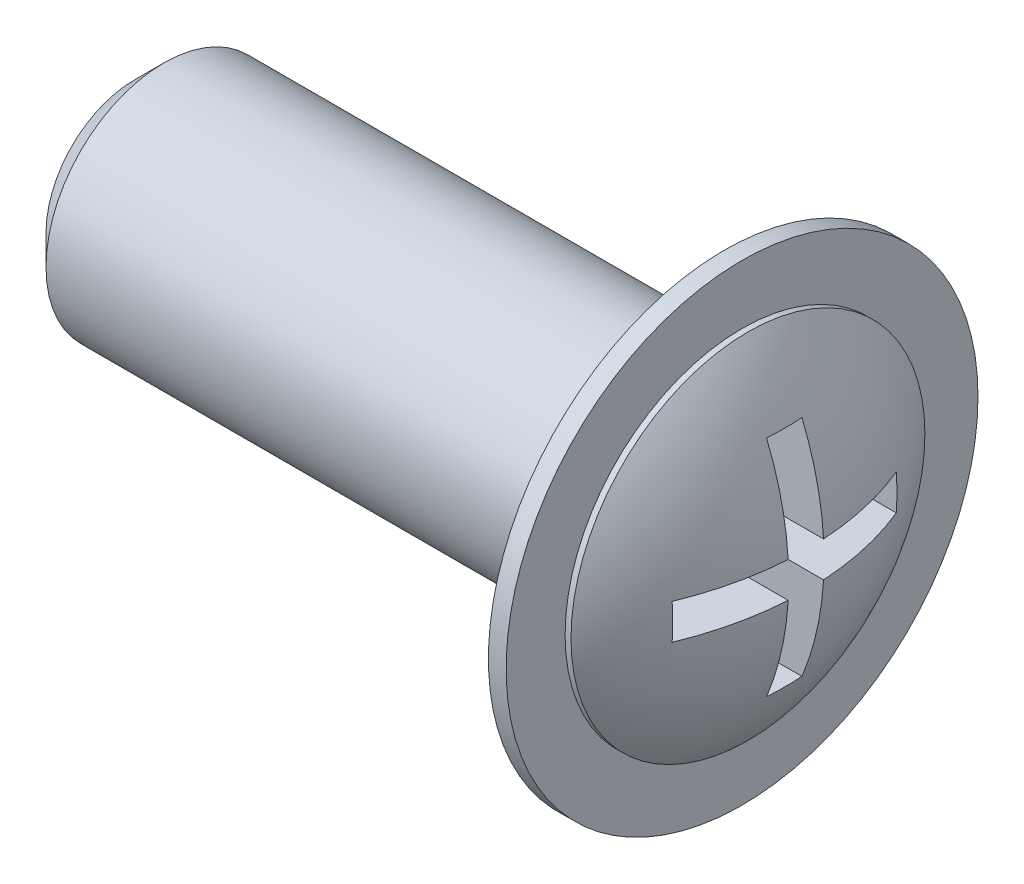
from build123d import *

# Parameters (mm, degrees)
SKETCH_1_R          = 4
EXTRUDE_1_DEPTH     = 0.3
SKETCH_2_R          = 2
EXTRUDE_3_DEPTH     = 10
SKETCH_6_R          = 3
EXTRUDE_4_DEPTH     = 0.1
DOME_1_FACE_RADIUS  = 3
DOME_1_HEIGHT       = 1
CUT_EXTRUDE_2_DEPTH = 3
CHAMFER_1_SIZE      = 0.5


with BuildPart() as part:
    # Sketch 1 → Extrude 1 (new body)
    with BuildSketch(Plane(origin=(0, 0, 0), x_dir=(0, 0, -1), z_dir=(1, 0, 0))):
        Circle(SKETCH_1_R)
    extrude(amount=EXTRUDE_1_DEPTH)

    # Sketch 2 → Extrude 3 (add)
    with BuildSketch(Plane.ZY):
        Circle(SKETCH_2_R)
    extrude(amount=EXTRUDE_3_DEPTH)

    # Sketch 6 → Extrude 4 (add)
    with BuildSketch(Plane(origin=(0.3, 0, 0), x_dir=(0, 0, -1), z_dir=(1, 0, 0))):
        Circle(SKETCH_6_R)
    extrude(amount=EXTRUDE_4_DEPTH)

    # Dome 1: a dome of height H over a round flat face of radius A is a cap of a sphere of radius (A * A + H * H) / (2 * H)
    dome_1_r = (DOME_1_FACE_RADIUS * DOME_1_FACE_RADIUS + DOME_1_HEIGHT * DOME_1_HEIGHT) / (2 * DOME_1_HEIGHT)
    dome_1_base = Plane((0.4, 0, 0), z_dir=(1, 0, 0))
    with Locations(dome_1_base.offset(DOME_1_HEIGHT - dome_1_r)):
        dome_1_ball = Sphere(dome_1_r, mode=Mode.PRIVATE)
    add(split(dome_1_ball, bisect_by=dome_1_base, keep=Keep.TOP, mode=Mode.PRIVATE))

    # Sketch 5 → Cut-Extrude 2 (cut)
    with BuildSketch(Plane(origin=(0, 0, 0), x_dir=(0, 0, -1), z_dir=(1, 0, 0))):
        Polygon((0.3, 0.3), (1.9, 0.3), (1.9, -0.3), (0.3, -0.3), (0.3, -1.9), (-0.3, -1.9), (-0.3, -0.3), (-1.9, -0.3), (-1.9, 0.3), (-0.3, 0.3), (-0.3, 1.9), (0.3, 1.9), align=None)
    extrude(amount=CUT_EXTRUDE_2_DEPTH, mode=Mode.SUBTRACT)

    # Chamfer 1
    chamfer_1_edges = [part.edges().sort_by_distance(p)[0] for p in [
        (-10, 0, -2),
    ]]
    chamfer(chamfer_1_edges, length=CHAMFER_1_SIZE)


solid = part.part
